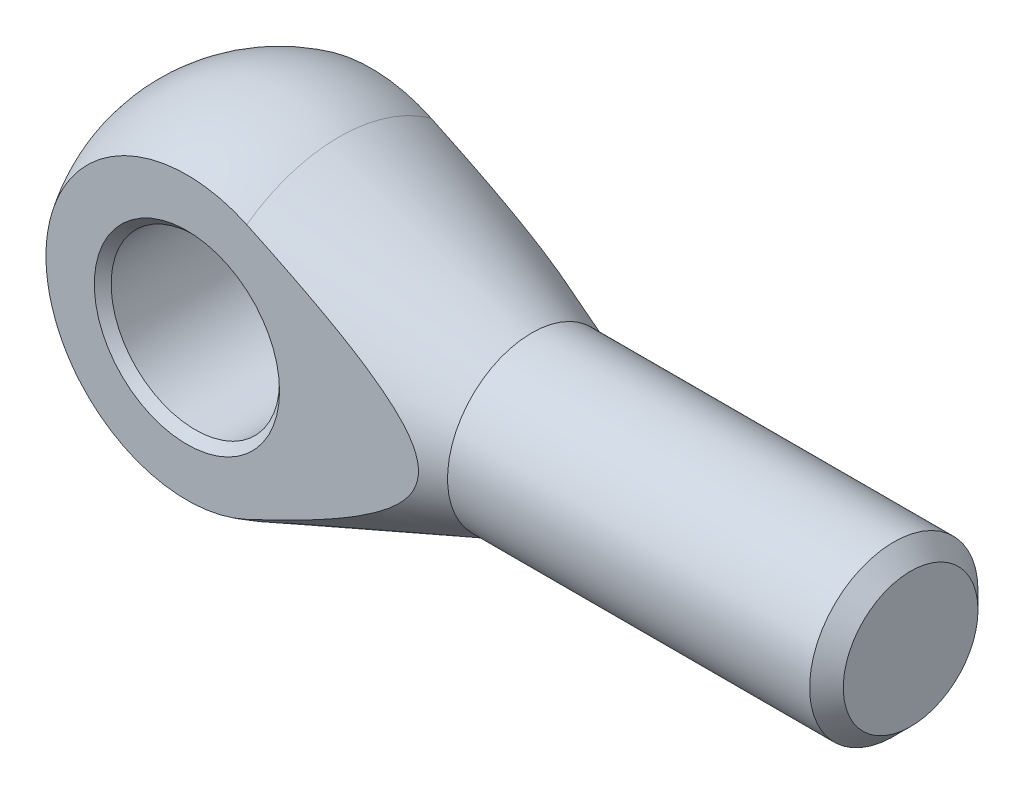
from build123d import *

# Parameters (mm, degrees)
SKICA2_OUTSIDE_W              = 119.114
SKICA2_OUTSIDE_H              = 64.114
SKICA2_OUTSIDE_W_2            = 160.751096763
SKICA2_OUTSIDE_H_2            = 21.9
ODEBRAT_VYSUNUT_M1_DEPTH      = 21
ODEBRAT_VYSUNUT_M1_DEPTH_BACK = 21
SKICA3_R                      = 10
ODEBRAT_VYSUNUT_M2_DEPTH      = 11.95
ODEBRAT_VYSUNUT_M2_DEPTH_BACK = 11.95
ZKOSEN_1_SIZE                 = 1
ZKOSEN_2_SIZE                 = 2


with BuildPart() as part:
    # Skica1 → Rotovat1 (revolve)
    with BuildSketch(Plane.XY, mode=Mode.PRIVATE) as rotovat1_sk:
        with BuildLine():
            Line((7.101020514, 18.696938457), (30, 10))
            Line((30, 10), (75, 10))
            Line((75, 10), (75, 0))
            Line((75, 0), (-20, 0))
            ThreePointArc((-20, 0), (-11.357367426, 16.462387589), (7.101020514, 18.696938457))
        make_face()
    revolve(rotovat1_sk.sketch.rotate(Axis((0, 0, 0), (-1, 0, 0)), 90), axis=Axis((0, 0, 0), (-1, 0, 0)))  # turned: the seam where the file's is

    # Skica2 outside → Odebrat vysunutím1 (cut, two sides)
    with BuildSketch(Plane(origin=(0, 0, 0), x_dir=(1, 0, 0), z_dir=(0, 1, 0))) as odebrat_vysunut_m1_sk:
        with Locations((27.5, 0)):
            Rectangle(SKICA2_OUTSIDE_W, SKICA2_OUTSIDE_H)
        with Locations((14.564667135, 0)):
            Rectangle(SKICA2_OUTSIDE_W_2, SKICA2_OUTSIDE_H_2, mode=Mode.SUBTRACT)
    extrude(amount=ODEBRAT_VYSUNUT_M1_DEPTH, mode=Mode.SUBTRACT)
    extrude(odebrat_vysunut_m1_sk.sketch, amount=-ODEBRAT_VYSUNUT_M1_DEPTH_BACK, mode=Mode.SUBTRACT)

    # Skica3 → Odebrat vysunutím2 (cut, two sides)
    with BuildSketch(Plane.XY) as odebrat_vysunut_m2_sk:
        Circle(SKICA3_R)
    extrude(amount=ODEBRAT_VYSUNUT_M2_DEPTH, mode=Mode.SUBTRACT)
    extrude(odebrat_vysunut_m2_sk.sketch, amount=-ODEBRAT_VYSUNUT_M2_DEPTH_BACK, mode=Mode.SUBTRACT)

    # Zkosení1
    zkosen_1_edges = [part.edges().sort_by_distance(p)[0] for p in [
        (-10, 0, -10.95),
        (-10, 0, 10.95),
    ]]
    chamfer(zkosen_1_edges, length=ZKOSEN_1_SIZE)

    # Zkosení2
    zkosen_2_edges = [part.edges().sort_by_distance(p)[0] for p in [
        (75, 0, 10),
    ]]
    chamfer(zkosen_2_edges, length=ZKOSEN_2_SIZE)


solid = part.part
